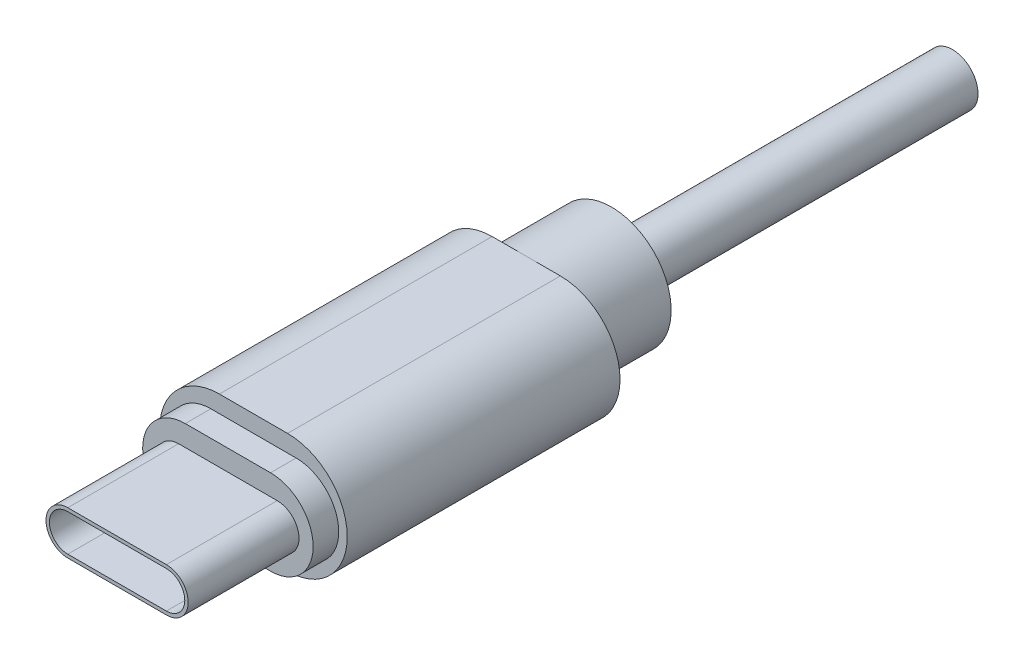
from build123d import *

# Parameters (mm, degrees)
BOSS_EXTRUDE1_DEPTH = 16
BOSS_EXTRUDE2_DEPTH = 1.5
BOSS_EXTRUDE3_DEPTH = 6.5
CUT_EXTRUDE1_DEPTH  = 6.3
SKETCH6_R           = 1.5
CUT_EXTRUDE2_DEPTH  = 80


with BuildPart() as part:
    # Sketch1 → Boss-Extrude1 (new body)
    with BuildSketch(Plane.XY.offset(-1.5)):
        with BuildLine():
            Line((2, 3.5), (-2, 3.5))
            ThreePointArc((-2, 3.5), (-5.5, 0), (-2, -3.5))
            Line((-2, -3.5), (2, -3.5))
            ThreePointArc((2, -3.5), (5.5, 0), (2, 3.5))
        make_face()
    extrude(amount=-BOSS_EXTRUDE1_DEPTH)

    # Sketch2 → Boss-Extrude2 (add)
    with BuildSketch(Plane.XY.offset(-1.5)):
        with BuildLine():
            Line((2.5, -2.5), (-2.5, -2.5))
            ThreePointArc((-2.5, -2.5), (-5, 0), (-2.5, 2.5))
            Line((-2.5, 2.5), (2.5, 2.5))
            ThreePointArc((2.5, 2.5), (5, 0), (2.5, -2.5))
        make_face()
    extrude(amount=BOSS_EXTRUDE2_DEPTH)

    # Sketch3 → Boss-Extrude3 (add)
    with BuildSketch(Plane.XY):
        with BuildLine():
            Line((2.89, -1.28), (-2.89, -1.28))
            ThreePointArc((-2.89, -1.28), (-4.17, 0), (-2.89, 1.28))
            Line((-2.89, 1.28), (2.89, 1.28))
            ThreePointArc((2.89, 1.28), (4.17, 0), (2.89, -1.28))
        make_face()
    extrude(amount=BOSS_EXTRUDE3_DEPTH)

    # Sketch4 → Cut-Extrude1 (cut)
    with BuildSketch(Plane.XY.offset(6.5)):
        with BuildLine():
            Line((2.89, 1.08), (-2.89, 1.08))
            ThreePointArc((-2.89, 1.08), (-3.97, 0), (-2.89, -1.08))
            Line((-2.89, -1.08), (2.89, -1.08))
            ThreePointArc((2.89, -1.08), (3.97, 0), (2.89, 1.08))
        make_face()
    extrude(amount=-CUT_EXTRUDE1_DEPTH, mode=Mode.SUBTRACT)

    # Sketch5 → Revolve1 (revolve)
    with BuildSketch(Plane.XZ):
        Polygon((3.5, -17.5), (0, -17.5), (0, -122.5), (1.5, -122.5), (1.5, -22.5), (3.5, -22.5), align=None)
    revolve(axis=Axis((0, 0, -17.5), (0, 0, -1)))

    # Sketch6 → Cut-Extrude2 (cut)
    with BuildSketch(Plane(origin=(0, 0, -122.5), x_dir=(-1, 0, 0), z_dir=(0, 0, -1))):
        Circle(SKETCH6_R)
    extrude(amount=-CUT_EXTRUDE2_DEPTH, mode=Mode.SUBTRACT)


solid = part.part
